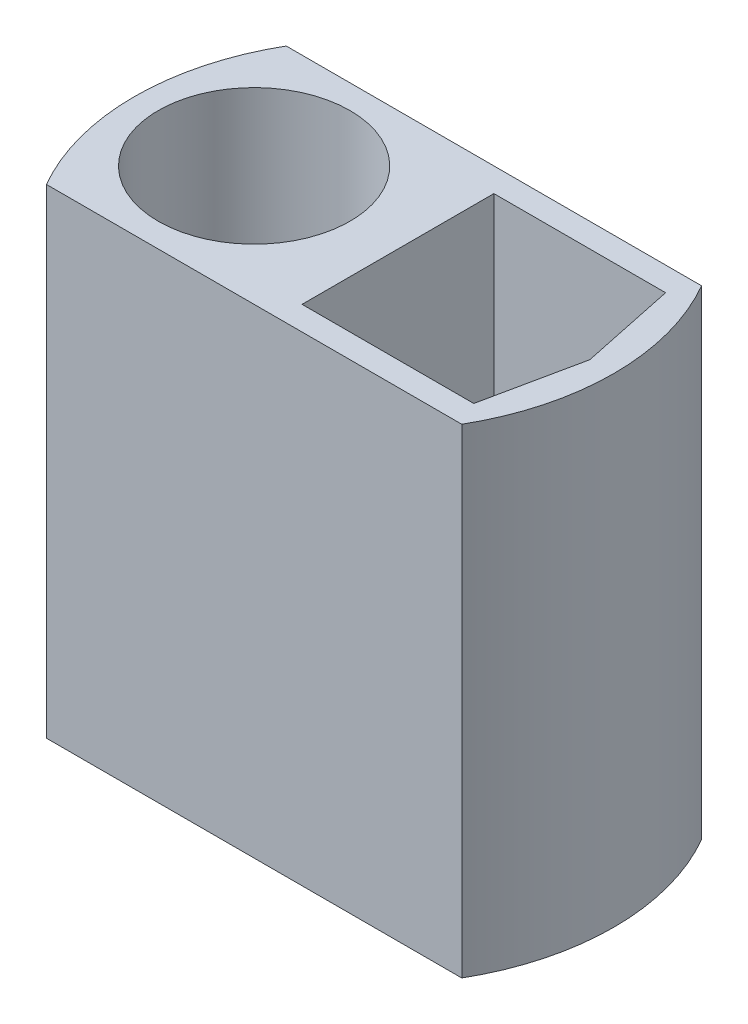
from build123d import *

# Parameters (mm, degrees)
SKETCH1_R           = 5.08
BOSS_EXTRUDE4_DEPTH = 25.4
SKETCH1_9_R         = 0.635
SKETCH1_9_R_2       = 5.08
BOSS_EXTRUDE5_DEPTH = 1.27


with BuildPart() as part:
    # Sketch1 → Boss-Extrude4 (new body)
    with BuildSketch(Plane(origin=(0, 0, 0), x_dir=(1, 0, 0), z_dir=(0, 1, 0))):
        with BuildLine():
            Line((10.998522628, 6.35), (-7.775388174, 6.35))
            Line((-7.775388174, 6.35), (-10.998522628, 6.35))
            ThreePointArc((-10.998522628, 6.35), (-12.7, 0), (-10.998522628, -6.35))
            Line((-10.998522628, -6.35), (10.998522628, -6.35))
            ThreePointArc((10.998522628, -6.35), (12.267257994, -3.287001873), (12.7, 0))
            ThreePointArc((12.7, 0), (12.267257994, 3.287001873), (10.998522628, 6.35))
        make_face()
        with Locations((-6.35, 0)):
            Circle(SKETCH1_R, mode=Mode.SUBTRACT)
        Polygon((1.27, -5.08), (1.27, 0), (1.27, 5.08), (10.363946118, 5.08), (11.43, 0), (10.363946118, -5.08), align=None, mode=Mode.SUBTRACT)
    extrude(amount=BOSS_EXTRUDE4_DEPTH)

    # Sketch1_9 → Boss-Extrude5 (add)
    # profile 1 of 2: a face of its own
    with BuildSketch(Plane(origin=(0, 0, 0), x_dir=(1, 0, 0), z_dir=(0, 1, 0))):
        Polygon((1.27, 5.08), (1.27, -5.08), (10.363946118, -5.08), (11.43, 0), (10.363946118, 5.08), align=None)
        with Locations((3.528103699, 2.54)):
            Circle(SKETCH1_9_R, mode=Mode.SUBTRACT)
        with Locations((6.35, 2.54)):
            Circle(SKETCH1_9_R, mode=Mode.SUBTRACT)
        with Locations((9.202180779, 2.54)):
            Circle(SKETCH1_9_R, mode=Mode.SUBTRACT)
    # profile 2 of 2: a face of its own
    with BuildSketch(Plane(origin=(0, 0, 0), x_dir=(1, 0, 0), z_dir=(0, 1, 0))):
        with Locations((-6.35, 0)):
            Circle(SKETCH1_9_R_2)
        with Locations((-7.62, 0)):
            Circle(SKETCH1_9_R, mode=Mode.SUBTRACT)
        with Locations((-5.08, 0)):
            Circle(SKETCH1_9_R, mode=Mode.SUBTRACT)
    extrude(amount=BOSS_EXTRUDE5_DEPTH)


solid = part.part
